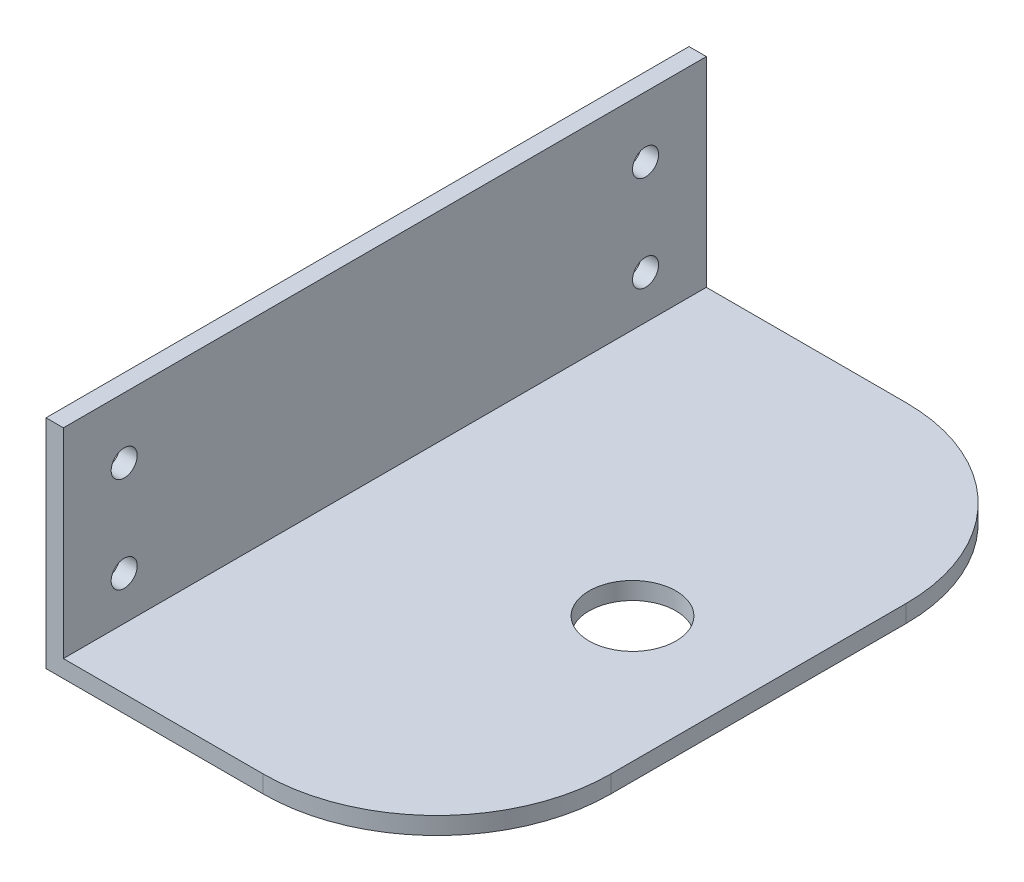
from build123d import *

# Parameters (mm, degrees)
SKETCH1_W               = 45
SKETCH1_H               = 74
SKETCH1_R               = 5
BOSS_EXTRUDE1_DEPTH     = 2
SKETCH2_W               = 2
SKETCH2_H               = 74
BOSS_EXTRUDE2_DEPTH     = 23
SKETCH3_R               = 1.5
CUT_EXTRUDE1_DEPTH      = 44
CUT_EXTRUDE1_DEPTH_BACK = 3
FILLET1_R               = 20


with BuildPart() as part:
    # Sketch1 → Boss-Extrude1 (new body)
    with BuildSketch(Plane(origin=(0, 0, 0), x_dir=(1, 0, 0), z_dir=(0, 1, 0))):
        with Locations((-8, 0)):
            Rectangle(SKETCH1_W, SKETCH1_H)
        Circle(SKETCH1_R, mode=Mode.SUBTRACT)
    extrude(amount=BOSS_EXTRUDE1_DEPTH)

    # Sketch2 → Boss-Extrude2 (add)
    with BuildSketch(Plane(origin=(0, 2, 0), x_dir=(1, 0, 0), z_dir=(0, 1, 0))):
        with Locations((-29.5, 0)):
            Rectangle(SKETCH2_W, SKETCH2_H)
    extrude(amount=BOSS_EXTRUDE2_DEPTH)

    # Sketch3 → Cut-Extrude1 (cut, two sides)
    with BuildSketch(Plane(origin=(-28.5, 0, 0), x_dir=(0, 0, -1), z_dir=(1, 0, 0))) as cut_extrude1_sk:
        with Locations((-30, 18)):
            Circle(SKETCH3_R)
        with Locations((-30, 7)):
            Circle(SKETCH3_R)
        with Locations((30, 7)):
            Circle(SKETCH3_R)
        with Locations((30, 18)):
            Circle(SKETCH3_R)
    extrude(amount=CUT_EXTRUDE1_DEPTH, mode=Mode.SUBTRACT)
    extrude(cut_extrude1_sk.sketch, amount=-CUT_EXTRUDE1_DEPTH_BACK, mode=Mode.SUBTRACT)

    # Fillet1
    fillet1_edges = [part.edges().sort_by_distance(p)[0] for p in [
        (14.5, 1, -37),
        (14.5, 1, 37),
    ]]
    fillet(fillet1_edges, radius=FILLET1_R)


solid = part.part
